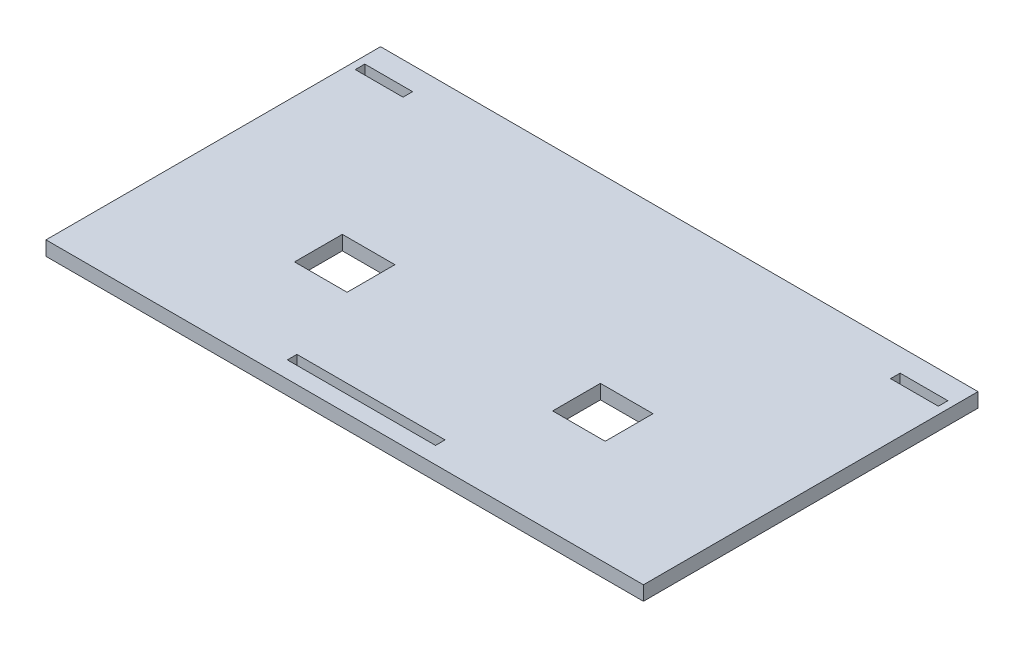
from build123d import *

# Parameters (mm, degrees)
CROQUIS1_W              = 125
CROQUIS1_H              = 70
SALIENTE_EXTRUIR1_DEPTH = 3
CROQUIS2_W              = 10
CROQUIS2_H              = 2
CORTAR_EXTRUIR1_DEPTH   = 10
CROQUIS3_W              = 31
CROQUIS3_H              = 2
CORTAR_EXTRUIR2_DEPTH   = 10
CROQUIS4_W              = 11
CROQUIS4_H              = 10
CORTAR_EXTRUIR3_DEPTH   = 10


with BuildPart() as part:
    # Croquis1 → Saliente-Extruir1 (new body)
    with BuildSketch(Plane(origin=(0, 0, 0), x_dir=(1, 0, 0), z_dir=(0, 1, 0))):
        Rectangle(CROQUIS1_W, CROQUIS1_H)
    extrude(amount=SALIENTE_EXTRUIR1_DEPTH)

    # Croquis2 → Cortar-Extruir1 (cut)
    with BuildSketch(Plane(origin=(0, 3, 0), x_dir=(1, 0, 0), z_dir=(0, 1, 0))):
        with Locations((-56, 29.2)):
            Rectangle(CROQUIS2_W, CROQUIS2_H)
        with Locations((56, 29.2)):
            Rectangle(CROQUIS2_W, CROQUIS2_H)
    extrude(amount=-CORTAR_EXTRUIR1_DEPTH, mode=Mode.SUBTRACT)

    # Croquis3 → Cortar-Extruir2 (cut)
    with BuildSketch(Plane(origin=(0, 3, 0), x_dir=(1, 0, 0), z_dir=(0, 1, 0))):
        with Locations((0, -30.5)):
            Rectangle(CROQUIS3_W, CROQUIS3_H)
    extrude(amount=-CORTAR_EXTRUIR2_DEPTH, mode=Mode.SUBTRACT)

    # Croquis4 → Cortar-Extruir3 (cut)
    with BuildSketch(Plane(origin=(0, 3, 0), x_dir=(1, 0, 0), z_dir=(0, 1, 0))):
        with Locations((-27, -8)):
            Rectangle(CROQUIS4_W, CROQUIS4_H)
        with Locations((27, -8)):
            Rectangle(CROQUIS4_W, CROQUIS4_H)
    extrude(amount=-CORTAR_EXTRUIR3_DEPTH, mode=Mode.SUBTRACT)


solid = part.part
